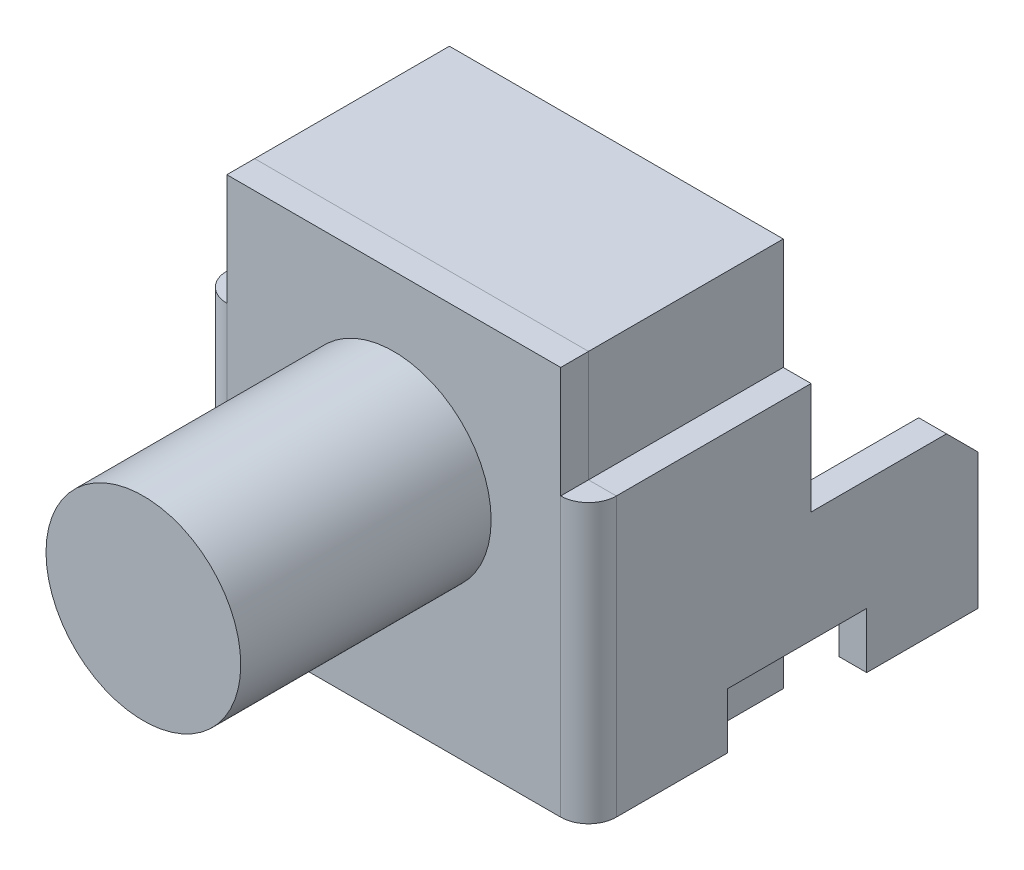
from build123d import *

# Parameters (mm, degrees)
EXTRUDE_1_DEPTH = 0.5
SKETCH_1_3_W    = 1.5
SKETCH_1_3_H    = 1
SKETCH_1_3_W_2  = 3.5
SKETCH_1_3_H_2  = 2
EXTRUDE_2_DEPTH = 6
EXTRUDE_START   = -6
EXTRUDE_3_DEPTH = 0.5
SKETCH_2_R      = 1.75
EXTRUDE_4_DEPTH = 5
SKETCH_3_W      = 6
SKETCH_3_H      = 7
SKETCH_3_R      = 1.75
EXTRUDE_5_DEPTH = 0.5
SKETCH_5_W      = 0.5
SKETCH_5_H      = 5
REVOLVE_1_ANGLE = 90
SKETCH_6_W      = 0.5
SKETCH_6_H      = 5
REVOLVE_2_ANGLE = 90


with BuildPart() as part:
    # Sketch 1 → Extrude 1 (new body)
    with BuildSketch(Plane(origin=(0, 0, 0), x_dir=(0, 0, -1), z_dir=(1, 0, 0))):
        Polygon((0, 5), (0, 0), (2, 0), (2, 1), (4.5, 1), (4.5, 0), (6.5, 0), (6.5, 2.434314575), (5.934314575, 3), (3.5, 3), (3.5, 5), align=None)
    extrude(amount=EXTRUDE_1_DEPTH)


with BuildPart() as body_2:
    # Sketch 1_3 → Extrude 2 (new body)
    with BuildSketch(Plane(origin=(0, 0, 0), x_dir=(0, 0, -1), z_dir=(1, 0, 0))):
        with Locations((2.75, 0.5)):
            Rectangle(SKETCH_1_3_W, SKETCH_1_3_H)
        Polygon((0, 5), (0, 0), (2, 0), (2, 1), (3.5, 1), (3.5, 3), (3.5, 5), align=None)
        with Locations((1.75, 6)):
            Rectangle(SKETCH_1_3_W_2, SKETCH_1_3_H_2)
    extrude(amount=-EXTRUDE_2_DEPTH)


with BuildPart() as body_3:
    # Sketch 1_4 → Extrude 3 (new body)
    with BuildSketch(Plane(origin=(0, 0, 0), x_dir=(0, 0, -1), z_dir=(1, 0, 0)).offset(EXTRUDE_START)):
        Polygon((5.934314575, 3), (3.5, 3), (3.5, 1), (4.5, 1), (4.5, 0), (6.5, 0), (6.5, 2.434314575), align=None)
        Polygon((0, 5), (0, 0), (2, 0), (2, 1), (3.5, 1), (3.5, 3), (3.5, 5), align=None)
    extrude(amount=-EXTRUDE_3_DEPTH)


with BuildPart() as body_4:
    # Sketch 2 → Extrude 4 (new body)
    with BuildSketch(Plane.XY):
        with Locations((-3, 4)):
            Circle(SKETCH_2_R)
    extrude(amount=EXTRUDE_4_DEPTH)


with BuildPart() as body_5:
    # Sketch 3 → Extrude 5 (new body)
    with BuildSketch(Plane.XY):
        with Locations((-3, 3.5)):
            Rectangle(SKETCH_3_W, SKETCH_3_H)
        with Locations((-3, 4)):
            Circle(SKETCH_3_R, mode=Mode.SUBTRACT)
    extrude(amount=EXTRUDE_5_DEPTH)


with BuildPart() as body_6:
    # Sketch 5 → Revolve 1 (revolve)
    with BuildSketch(Plane.XY):
        with Locations((-6.25, 2.5)):
            Rectangle(SKETCH_5_W, SKETCH_5_H)
    revolve(axis=Axis((-6, 0, 0), (0, 1, 0)), revolution_arc=REVOLVE_1_ANGLE)


with BuildPart() as body_7:
    # Sketch 6 → Revolve 2 (revolve)
    with BuildSketch(Plane.XY):
        with Locations((0.25, 2.5)):
            Rectangle(SKETCH_6_W, SKETCH_6_H)
    revolve(axis=Axis((0, 5, 0), (0, -1, 0)), revolution_arc=REVOLVE_2_ANGLE)


solid = Compound([part.part, body_2.part, body_3.part, body_4.part, body_5.part, body_6.part, body_7.part])
